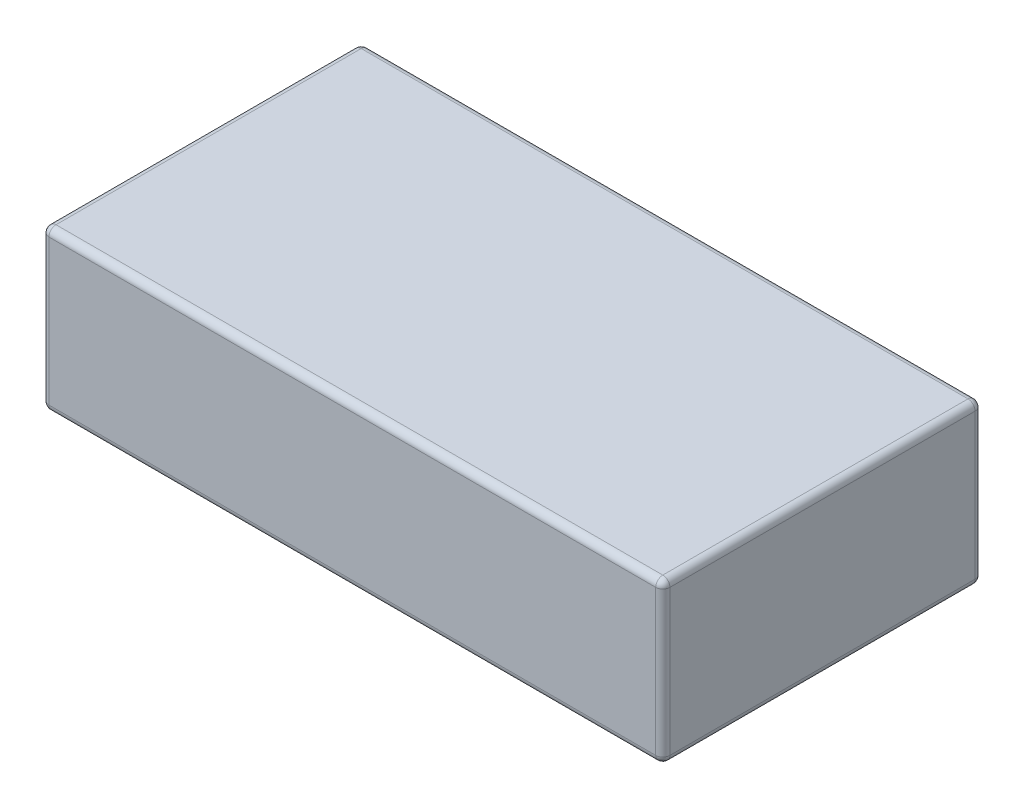
from build123d import *

# Parameters (mm, degrees)
SKETCH1_W           = 175
SKETCH1_H           = 45
BOSS_EXTRUDE1_DEPTH = 90
FILLET1_R           = 2


with BuildPart() as part:
    # Sketch1 → Boss-Extrude1 (new body)
    with BuildSketch(Plane.XY):
        Rectangle(SKETCH1_W, SKETCH1_H)
    extrude(amount=BOSS_EXTRUDE1_DEPTH)

    # Fillet1
    fillet1_edges = [part.edges().sort_by_distance(p)[0] for p in [
        (-87.5, 0, 90),
        (0, -22.5, 90),
        (87.5, 0, 90),
        (0, -22.5, 0),
        (-87.5, 0, 0),
        (0, 22.5, 0),
        (87.5, 0, 0),
        (0, 22.5, 90),
        (87.5, -22.5, 45),
        (-87.5, -22.5, 45),
        (-87.5, 22.5, 45),
        (87.5, 22.5, 45),
    ]]
    fillet(fillet1_edges, radius=FILLET1_R)


solid = part.part
